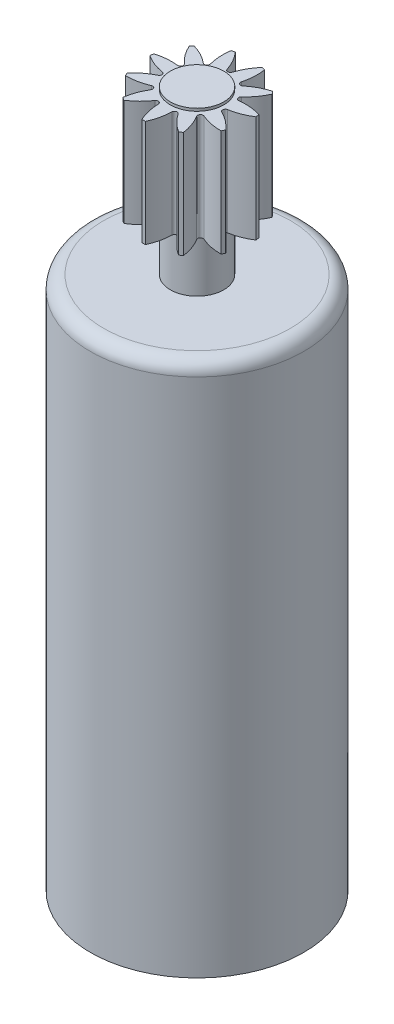
from build123d import *

# Parameters (mm, degrees)
CUT_EXTRUDE1_DEPTH = 4
CIRPATTERN1_COUNT  = 11


with BuildPart() as part:
    # Sketch1 → Revolve1 (revolve)
    with BuildSketch(Plane.XY):
        with BuildLine():
            Line((0, 0), (0, 26.1))
            Line((0, 26.1), (1, 26.1))
            Line((1, 26.1), (1, 26))
            Line((1, 26), (2, 26))
            Line((2, 26), (2, 22))
            Line((2, 22), (1, 22))
            Line((1, 22), (1, 20))
            Line((1, 20), (3.5, 20))
            ThreePointArc((3.5, 20), (3.853553391, 19.853553391), (4, 19.5))
            Line((4, 19.5), (4, 0))
            Line((4, 0), (0, 0))
        make_face()
    revolve(axis=Axis((0, 0, 0), (0, 1, 0)))

    # Sketch2 → Cut-Extrude1 (cut)
    with BuildSketch(Plane(origin=(0, 26, 0), x_dir=(1, 0, 0), z_dir=(0, 1, 0))):
        with BuildLine():
            ThreePointArc((-0.5, 1.936491673), (0, 2), (0.5, 1.936491673))
            ThreePointArc((0.5, 1.936491673), (0.260400333, 1.599188187), (0.095331419, 1.219801979))
            ThreePointArc((0.095331419, 1.219801979), (0, 1.15), (-0.095331419, 1.219801979))
            ThreePointArc((-0.095331419, 1.219801979), (-0.260400333, 1.599188187), (-0.5, 1.936491673))
        make_face()
    cut_extrude1 = extrude(amount=-CUT_EXTRUDE1_DEPTH, mode=Mode.SUBTRACT)

    # CirPattern1: Cut-Extrude1 ×11 about axis
    cirpattern1_axis = Axis((0, 0, 0), (0, 1, 0))
    for i in range(1, CIRPATTERN1_COUNT):
        add(cut_extrude1.rotate(cirpattern1_axis, i * 360 / CIRPATTERN1_COUNT), mode=Mode.SUBTRACT)


solid = part.part
